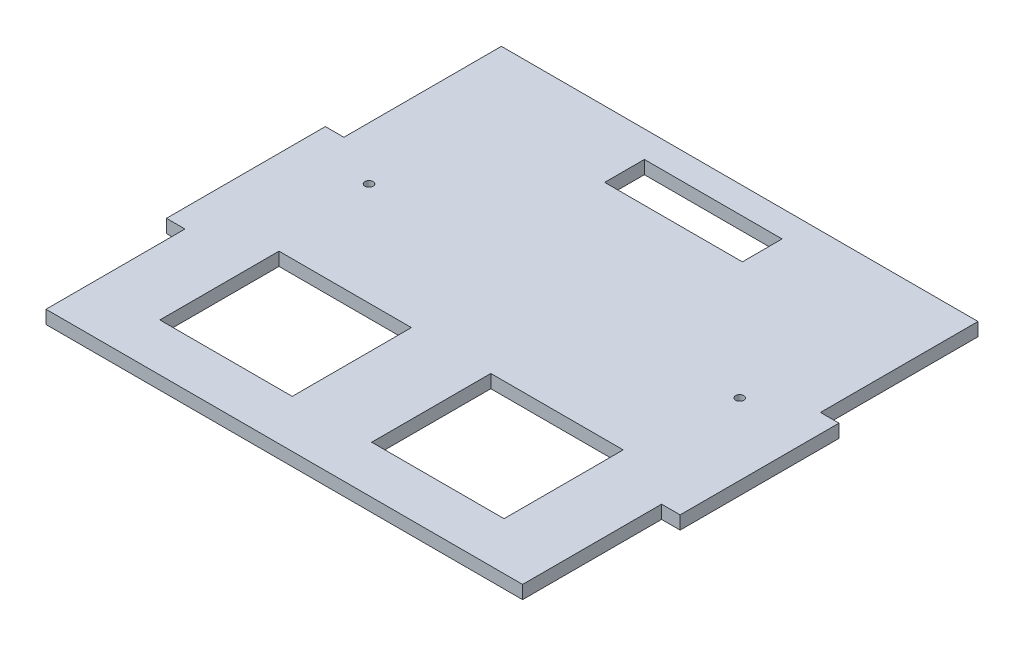
from build123d import *

# Parameters (mm, degrees)
SKETCH1_R           = 1.55
SKETCH1_W           = 52
SKETCH1_H           = 15
SKETCH1_W_2         = 50
SKETCH1_H_2         = 45
BOSS_EXTRUDE1_DEPTH = 5


with BuildPart() as part:
    # Sketch1 → Boss-Extrude1 (new body)
    with BuildSketch(Plane(origin=(0, 0, 0), x_dir=(1, 0, 0), z_dir=(0, 1, 0))):
        Polygon((90, 30), (97, 30), (97, -30), (90, -30), (90, -82.5), (-90, -82.5), (-90, -30), (-97, -30), (-97, 30), (-90, 30), (-90, 89.5), (90, 89.5), align=None)
        with Locations((70, 19.5)):
            Circle(SKETCH1_R, mode=Mode.SUBTRACT)
        with Locations((-70, 19.5)):
            Circle(SKETCH1_R, mode=Mode.SUBTRACT)
        with Locations((0, 72)):
            Rectangle(SKETCH1_W, SKETCH1_H, mode=Mode.SUBTRACT)
        with Locations((-40, -42)):
            Rectangle(SKETCH1_W_2, SKETCH1_H_2, mode=Mode.SUBTRACT)
        with Locations((40, -42)):
            Rectangle(SKETCH1_W_2, SKETCH1_H_2, mode=Mode.SUBTRACT)
    extrude(amount=BOSS_EXTRUDE1_DEPTH)


solid = part.part
